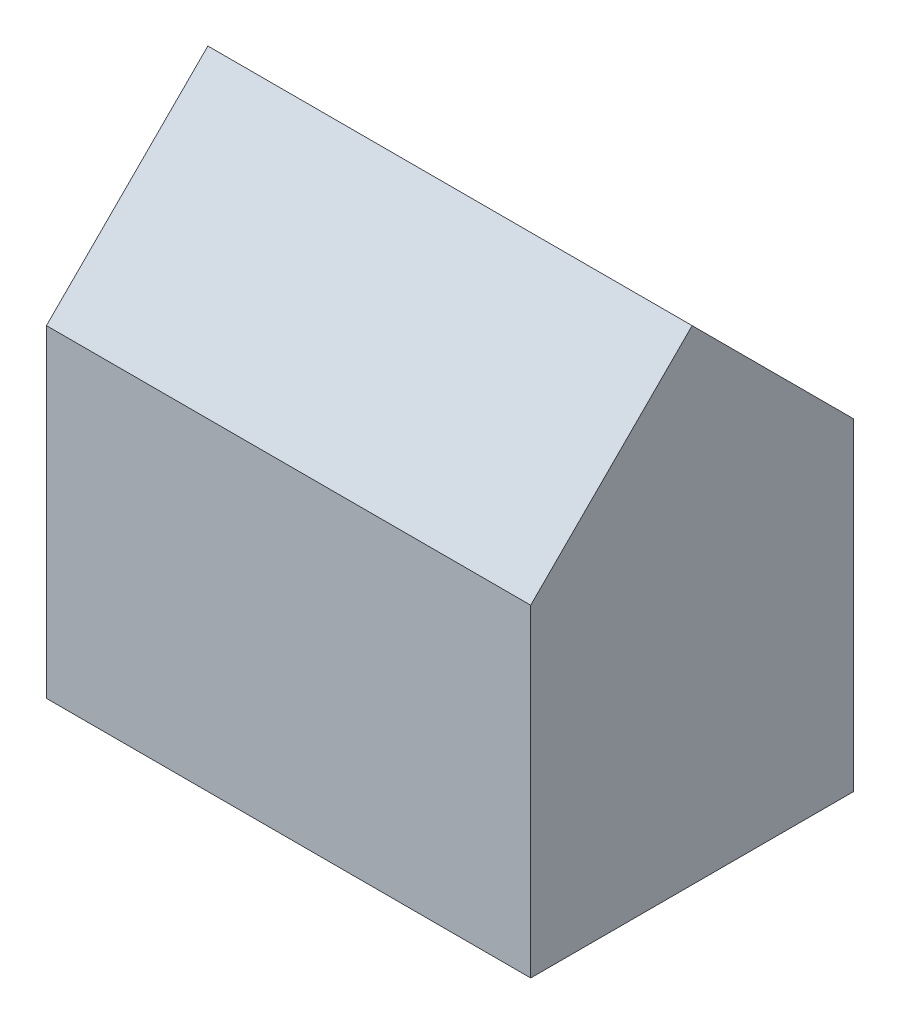
from build123d import *

# Parameters (mm, degrees)
SKETCH1_W           = 15
SKETCH1_H           = 10
SKETCH1_W_2         = 11
SKETCH1_H_2         = 6
BOSS_EXTRUDE1_DEPTH = 10
BOSS_EXTRUDE2_DEPTH = 15


with BuildPart() as part:
    # Sketch1 → Boss-Extrude1 (new body)
    with BuildSketch(Plane(origin=(0, 0, 0), x_dir=(1, 0, 0), z_dir=(0, 1, 0))):
        with Locations((7.5, 5)):
            Rectangle(SKETCH1_W, SKETCH1_H)
        with Locations((7.5, 5)):
            Rectangle(SKETCH1_W_2, SKETCH1_H_2, mode=Mode.SUBTRACT)
    extrude(amount=BOSS_EXTRUDE1_DEPTH)

    # Sketch2 → Boss-Extrude2 (add)
    with BuildSketch(Plane(origin=(15, 0, 0), x_dir=(0, 0, -1), z_dir=(1, 0, 0))):
        Polygon((0, 10), (5, 15), (10, 10), align=None)
    extrude(amount=-BOSS_EXTRUDE2_DEPTH)


solid = part.part
